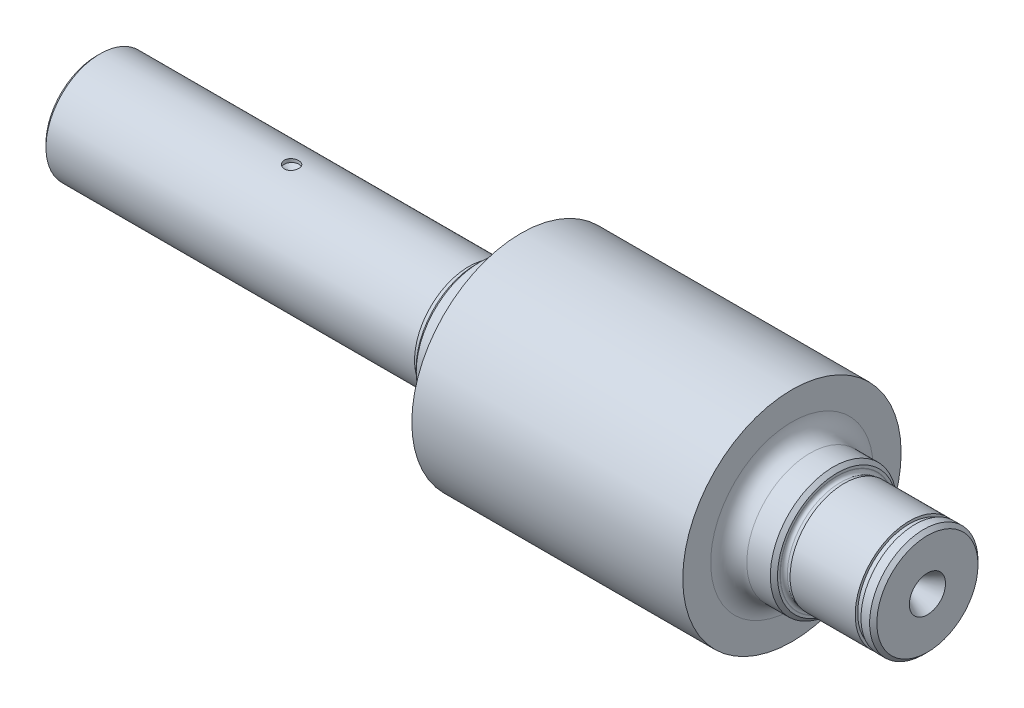
from build123d import *

# Parameters (mm, degrees)
FILLET1_R                      = 5
CHAMFER1_SIZE                  = 1
CHAMFER3_SIZE                  = 1
CUT_EXTRUDE3_REACH             = 21.325
SKETCH3_W                      = 60
SKETCH3_H                      = 8
F_2_5MM_DOWEL_HOLE1_D          = 2.5
F_2_5MM_DOWEL_HOLE1_DEPTH      = 5
F_2_5MM_DOWEL_HOLE1_TIP        = 0.751075774
CUT_EXTRUDE4_REACH             = 32.225
CUT_EXTRUDE4_DIRECTION_2_REACH = 32.225


with BuildPart() as part:
    # Sketch1 → Revolve1 (revolve)
    with BuildSketch(Plane.XY):
        with BuildLine():
            Line((230, 0), (0, 0))
            Line((0, 0), (0, 15))
            Line((0, 15), (103.027226573, 15))
            Line((103.027226573, 15), (104.045108577, 14.727259339))
            ThreePointArc((104.045108577, 14.727259339), (104.817849238, 14.934314575), (105.024904474, 15.707055236))
            Line((105.024904474, 15.707055236), (105, 15.8))
            Line((105, 15.8), (105, 17.5))
            Line((105, 17.5), (117.5, 17.5))
            Line((117.5, 17.5), (117.5, 30.225))
            Line((117.5, 30.225), (192.5, 30.225))
            Line((192.5, 30.225), (192.5, 17.5))
            Line((192.5, 17.5), (205, 17.5))
            Line((205, 17.5), (205, 15.8))
            Line((205, 15.8), (204.975095526, 15.707055236))
            ThreePointArc((204.975095526, 15.707055236), (205.182150762, 14.934314575), (205.954891423, 14.727259339))
            Line((205.954891423, 14.727259339), (206.972773427, 15))
            Line((206.972773427, 15), (225, 15))
            Line((225, 15), (225, 14.3))
            Line((225, 14.3), (226.6, 14.3))
            Line((226.6, 14.3), (226.6, 15))
            Line((226.6, 15), (230, 15))
            Line((230, 15), (230, 0))
        make_face()
    revolve(axis=Axis((230, 0, 0), (-1, 0, 0)))

    # Fillet1
    fillet1_edges = [part.edges().sort_by_distance(p)[0] for p in [
        (117.5, -17.5, 0),
        (192.5, -17.5, 0),
    ]]
    fillet(fillet1_edges, radius=FILLET1_R)

    # Chamfer1
    chamfer1_edges = [part.edges().sort_by_distance(p)[0] for p in [
        (105, -17.5, 0),
        (205, -17.5, 0),
    ]]
    chamfer(chamfer1_edges, length=CHAMFER1_SIZE)

    # Chamfer3
    chamfer3_edges = [part.edges().sort_by_distance(p)[0] for p in [
        (0, -15, 0),
        (230, -15, 0),
    ]]
    chamfer(chamfer3_edges, length=CHAMFER3_SIZE)

    # Sketch3 → Cut-Extrude3 (cut, up to next)
    with BuildSketch(Plane(origin=(0, -10.9, 0), x_dir=(1, 0, 0), z_dir=(0, 1, 0)), mode=Mode.PRIVATE) as cut_extrude3_sk1:
        with Locations((30, 0)):
            Rectangle(SKETCH3_W, SKETCH3_H)
    cut_extrude3_tool1 = extrude(cut_extrude3_sk1.sketch, amount=-CUT_EXTRUDE3_REACH, mode=Mode.PRIVATE) & part.part
    add(cut_extrude3_tool1.solids().sort_by_distance((30, -10.9, 0))[0], mode=Mode.SUBTRACT)

    # Sketch4 → Cut-Revolve1 (revolve, cut)
    with BuildSketch(Plane.XY):
        Polygon((54, 15), (54, 12.845299462), (52, 14), (52, 15), align=None)
    revolve(axis=Axis((54, 15, 0), (0, -1, 0)), mode=Mode.SUBTRACT)

    # Sketch8 → Cut-Revolve2 (revolve, cut)
    with BuildSketch(Plane(origin=(0, 0, 0), x_dir=(1, 0, 0), z_dir=(0, 1, 0))):
        Polygon((0, 5), (5.196152423, 2), (9, 2), (9.828427125, 0), (0, 0), align=None)
    cut_revolve2 = revolve(axis=Axis((9.828427125, 0, 0), (-1, 0, 0)), mode=Mode.SUBTRACT)

    # Mirror1: Cut-Revolve2 across plane
    add(cut_revolve2.mirror(Plane.ZY.offset(-115)), mode=Mode.SUBTRACT)

    # Ø2.5mm Dowel Hole1
    with Locations(Plane(origin=(0, -10.9, 0), x_dir=(-1, 0, 0), z_dir=(0, -1, 0))):
        with Locations((-30, 0)):
            Hole(F_2_5MM_DOWEL_HOLE1_D / 2, depth=F_2_5MM_DOWEL_HOLE1_DEPTH)
            with Locations((0, 0, -(F_2_5MM_DOWEL_HOLE1_DEPTH + F_2_5MM_DOWEL_HOLE1_TIP / 2))):  # 118° drill point
                Cone(0, F_2_5MM_DOWEL_HOLE1_D / 2, F_2_5MM_DOWEL_HOLE1_TIP, mode=Mode.SUBTRACT)

    # Cut-Extrude4: up to this face of the body (flat: up to its plane)
    cut_extrude4_end = Plane(part.part.faces().sort_by_distance((30.072424217, -12.67492082, -4))[0])
    # Sketch14 → Cut-Extrude4 (cut, up to the picked face)
    with BuildSketch(Plane.XY, mode=Mode.PRIVATE) as cut_extrude4_sk1:
        with BuildLine():
            Line((60, -15), (60, -10.9))
            ThreePointArc((60, -10.9), (65.403933752, -11.964795726), (70, -15))
            Line((70, -15), (60, -15))
        make_face()
    cut_extrude4_tool1 = split(extrude(cut_extrude4_sk1.sketch, amount=-CUT_EXTRUDE4_REACH, mode=Mode.PRIVATE), bisect_by=cut_extrude4_end, keep=Keep.BOTH, mode=Mode.PRIVATE)
    add(cut_extrude4_tool1.solids().sort_by_distance((63.834155, -13.337922, 0))[0], mode=Mode.SUBTRACT)

    # Cut-Extrude4 direction 2: up to this face of the body (flat: up to its plane)
    cut_extrude4_direction_2_end = Plane(part.part.faces().sort_by_distance((30.072424217, -12.67492082, 4))[0])
    # Sketch14 → Cut-Extrude4 direction 2 (cut, up to the picked face)
    with BuildSketch(Plane.XY, mode=Mode.PRIVATE) as cut_extrude4_direction_2_sk1:
        with BuildLine():
            Line((60, -15), (60, -10.9))
            ThreePointArc((60, -10.9), (65.403933752, -11.964795726), (70, -15))
            Line((70, -15), (60, -15))
        make_face()
    cut_extrude4_direction_2_tool1 = split(extrude(cut_extrude4_direction_2_sk1.sketch, amount=CUT_EXTRUDE4_DIRECTION_2_REACH, mode=Mode.PRIVATE), bisect_by=cut_extrude4_direction_2_end, keep=Keep.BOTH, mode=Mode.PRIVATE)
    add(cut_extrude4_direction_2_tool1.solids().sort_by_distance((63.834155, -13.337922, 0))[0], mode=Mode.SUBTRACT)


solid = part.part
